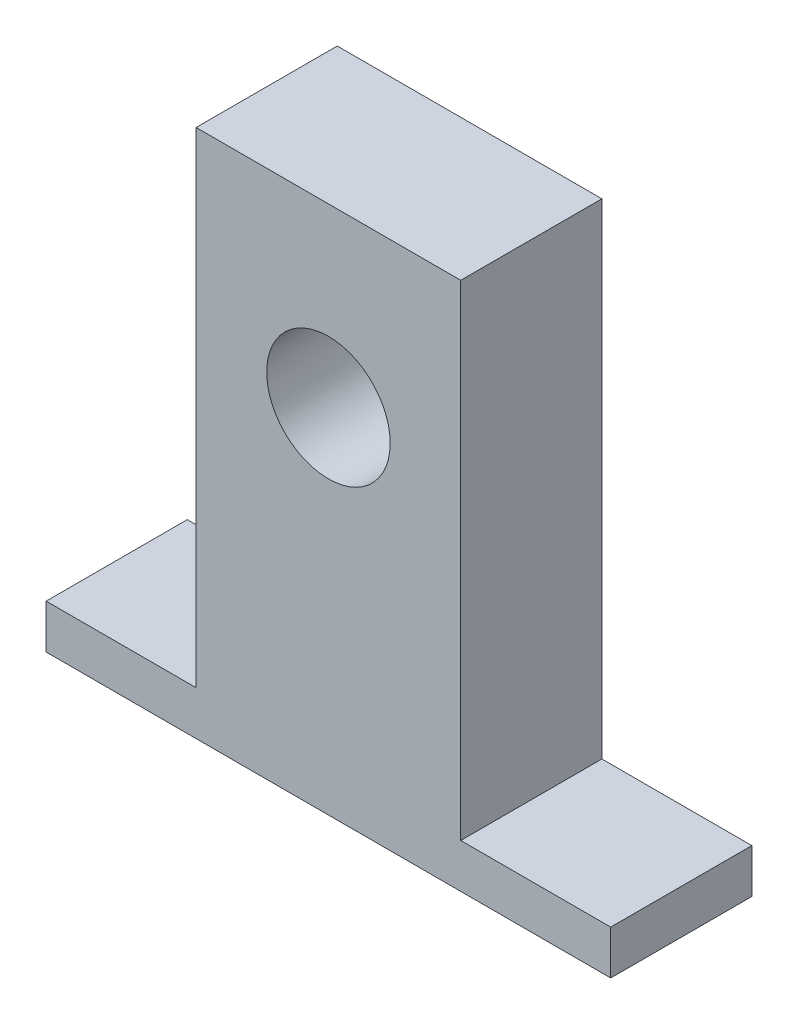
from build123d import *

# Parameters (mm, degrees)
SKETCH1_W           = 64
SKETCH1_H           = 16
BOSS_EXTRUDE1_DEPTH = 5
SKETCH2_W           = 30
SKETCH2_H           = 16
BOSS_EXTRUDE2_DEPTH = 55
SKETCH3_R           = 7
CUT_EXTRUDE1_DEPTH  = 55


with BuildPart() as part:
    # Sketch1 → Boss-Extrude1 (new body)
    with BuildSketch(Plane(origin=(0, 0, 0), x_dir=(1, 0, 0), z_dir=(0, 1, 0))):
        Rectangle(SKETCH1_W, SKETCH1_H)
    extrude(amount=BOSS_EXTRUDE1_DEPTH)

    # Sketch2 → Boss-Extrude2 (add)
    with BuildSketch(Plane(origin=(0, 5, 0), x_dir=(1, 0, 0), z_dir=(0, 1, 0))):
        Rectangle(SKETCH2_W, SKETCH2_H)
    extrude(amount=BOSS_EXTRUDE2_DEPTH)

    # Sketch3 → Cut-Extrude1 (cut)
    with BuildSketch(Plane.XY.offset(8)):
        with Locations((0, 40)):
            Circle(SKETCH3_R)
    extrude(amount=-CUT_EXTRUDE1_DEPTH, mode=Mode.SUBTRACT)


solid = part.part
